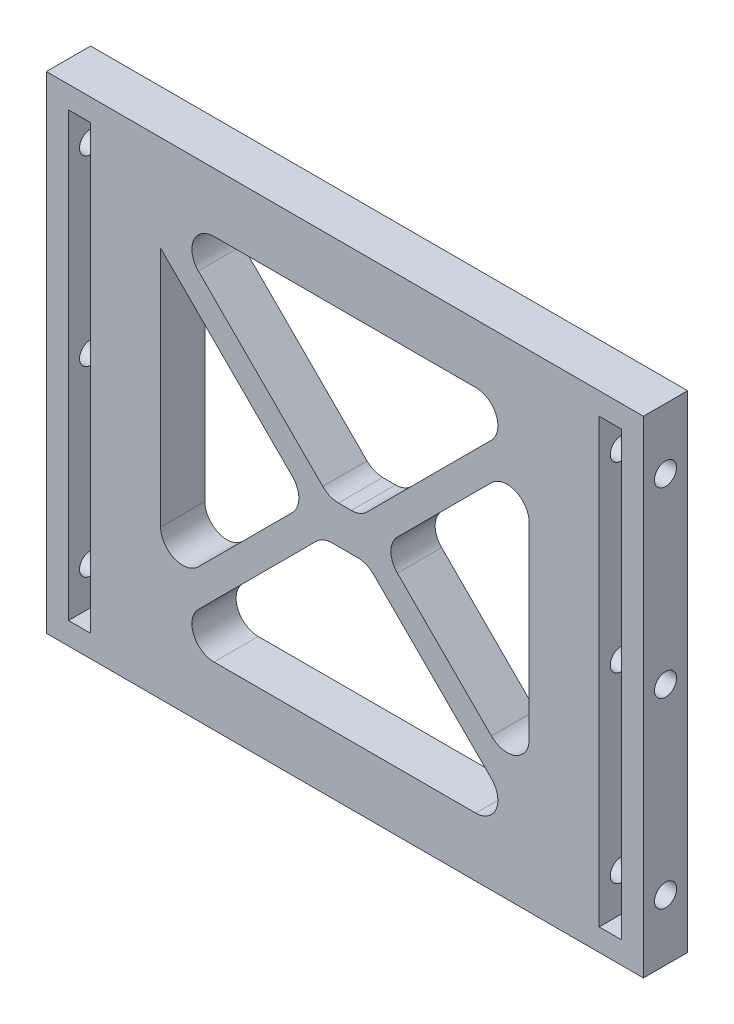
from build123d import *

# Parameters (mm, degrees)
SKETCH1_W           = 81
SKETCH1_H           = 66
BOSS_EXTRUDE1_DEPTH = 6
SKETCH3_W           = 3
SKETCH3_H           = 60
CUT_EXTRUDE2_DEPTH  = 7
CUT_EXTRUDE5_DEPTH  = 7
FILLET2_R           = 3
FILLET3_R           = 3
SKETCH6_R           = 1.5
CUT_EXTRUDE6_DEPTH  = 10


with BuildPart() as part:
    # Sketch1 → Boss-Extrude1 (new body)
    with BuildSketch(Plane.XY):
        Rectangle(SKETCH1_W, SKETCH1_H)
    extrude(amount=BOSS_EXTRUDE1_DEPTH)

    # Sketch3 → Cut-Extrude2 (cut, through all)
    with BuildSketch(Plane.XY.offset(6)):
        with Locations((-36, 0)):
            Rectangle(SKETCH3_W, SKETCH3_H)
        with Locations((36, 0)):
            Rectangle(SKETCH3_W, SKETCH3_H)
    extrude(amount=-CUT_EXTRUDE2_DEPTH, mode=Mode.SUBTRACT)

    # Sketch5 → Cut-Extrude5 (cut, through all)
    with BuildSketch(Plane.XY.offset(6)):
        Polygon((-5, 0), (-25, 20), (-25, -20), align=None)
        Polygon((-3, -3), (-25, -25), (0, -25), (0, -3), align=None)
        Polygon((0, -3), (0, -25), (25, -25), (3, -3), align=None)
        Polygon((25, -20), (25, 20), (5, 0), align=None)
        Polygon((25, 25), (0, 25), (0, 2.121320344), (2.121320344, 2.121320344), align=None)
        Polygon((0, 25), (-25, 25), (-2.121320344, 2.121320344), (0, 2.121320344), align=None)
    extrude(amount=-CUT_EXTRUDE5_DEPTH, mode=Mode.SUBTRACT)

    # Fillet2
    fillet2_edges = [part.edges().sort_by_distance(p)[0] for p in [
        (25, 20, 3),
        (25, -20, 3),
        (25, -25, 3),
        (-25, -25, 3),
        (-25, 25, 3),
        (25, 25, 3),
        (-25, -20, 3),
    ]]
    fillet(fillet2_edges, radius=FILLET2_R)

    # Fillet3
    fillet3_edges = [part.edges().sort_by_distance(p)[0] for p in [
        (5, 0, 3),
        (-3, -3, 3),
        (3, -3, 3),
        (2.121320344, 2.121320344, 3),
        (-2.121320344, 2.121320344, 3),
        (-5, 0, 3),
    ]]
    fillet(fillet3_edges, radius=FILLET3_R)

    # Sketch6 → Cut-Extrude6 (cut)
    with BuildSketch(Plane.ZY.offset(40.5)):
        with Locations((3, 24.75)):
            Circle(SKETCH6_R)
        with Locations((3, 0)):
            Circle(SKETCH6_R)
        with Locations((3, -24.75)):
            Circle(SKETCH6_R)
    cut_extrude6 = extrude(amount=-CUT_EXTRUDE6_DEPTH, mode=Mode.SUBTRACT)

    # Mirror1: Cut-Extrude6 across plane
    add(cut_extrude6.mirror(Plane(origin=(0, 0, 0), x_dir=(0, 0, 1), z_dir=(1, 0, 0))), mode=Mode.SUBTRACT)


solid = part.part
